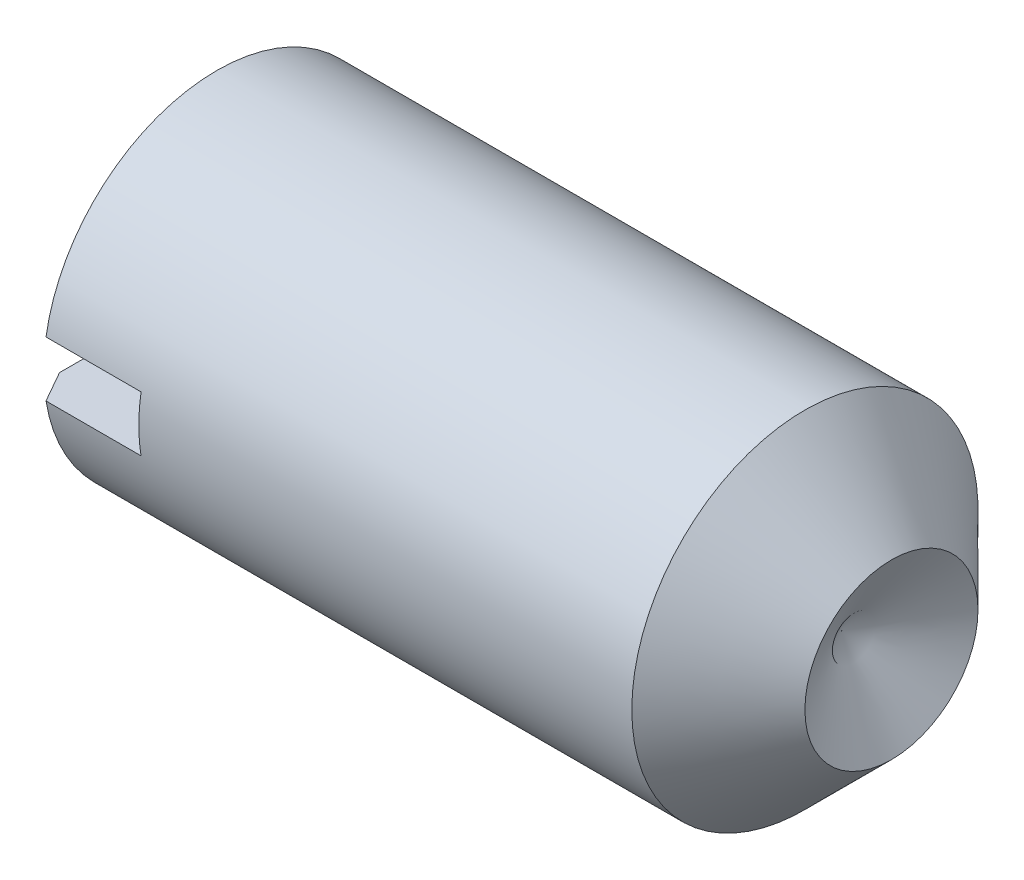
from build123d import *

# Parameters (mm, degrees)
SKETCH2_W  = 5
SKETCH2_H  = 0.8
SLOT_DEPTH = 1.63


with BuildPart() as part:
    # BodySke → BaseBody (revolve)
    with BuildSketch(Plane.XY):
        Polygon((10, 1.25), (9.278312164, 0), (0, 0), (0, 2.055), (0.25692087, 2.5), (8.75, 2.5), align=None)
    revolve(axis=Axis((-12.7, 0, 0), (1, 0, 0)))

    # Sketch2 → Slot (cut)
    with BuildSketch(Plane(origin=(0, 0, 0), x_dir=(0, 0, -1), z_dir=(1, 0, 0))):
        Rectangle(SKETCH2_W, SKETCH2_H)
    extrude(amount=SLOT_DEPTH, mode=Mode.SUBTRACT)


solid = part.part
